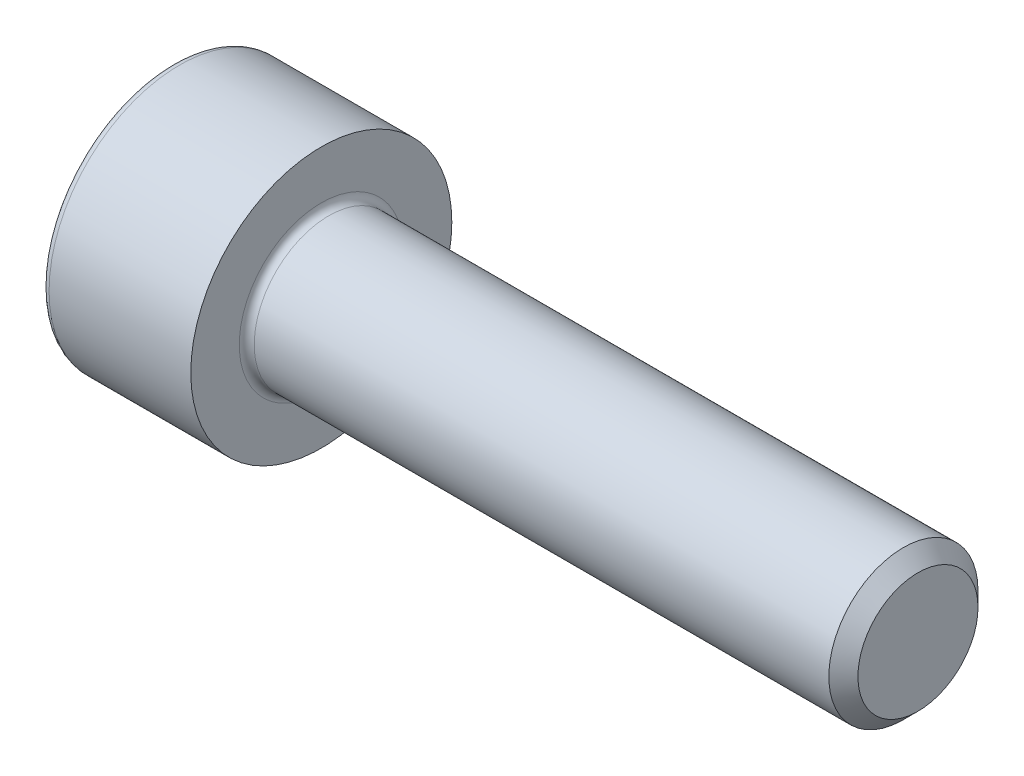
from build123d import *

# Parameters (mm, degrees)
ESBO_O1_W                = 4
ESBO_O1_H                = 3.5
ESBO_O2_R                = 2
RESSALTO_EXTRUS_O1_DEPTH = 16
CORTE_EXTRUS_O1_DEPTH    = 2
CHANFRO1_SIZE            = 0.39
FILETE1_R                = 0.2


with BuildPart() as part:
    # Esboço1 → Revolução1 (revolve)
    with BuildSketch(Plane(origin=(0, 0, 0), x_dir=(-1, 0, 0), z_dir=(0, 0, -1))):
        with Locations((-2, 1.75)):
            Rectangle(ESBO_O1_W, ESBO_O1_H)
    revolve(axis=Axis((4, 0, 0), (-1, 0, 0)))

    # Esboço2 → Ressalto-extrusão1 (add)
    with BuildSketch(Plane(origin=(4, 0, 0), x_dir=(0, 0, -1), z_dir=(1, 0, 0))):
        Circle(ESBO_O2_R)
    extrude(amount=RESSALTO_EXTRUS_O1_DEPTH)

    # Esboço3 → Corte-extrusão1 (cut)
    with BuildSketch(Plane.ZY):
        Polygon((0, -1.773042677), (1.5355, -0.886521338), (1.5355, 0.886521338), (0, 1.773042677), (-1.5355, 0.886521338), (-1.5355, -0.886521338), align=None)
    extrude(amount=-CORTE_EXTRUS_O1_DEPTH, mode=Mode.SUBTRACT)

    # Esboço4 → Corte-Revolução1 (revolve, cut)
    with BuildSketch(Plane.XY):
        Polygon((2, 1.5355), (2, 0), (2.886521338, 0), align=None)
    revolve(axis=Axis((2, 0, 0), (1, 0, 0)), mode=Mode.SUBTRACT)

    # Chanfro1
    chanfro1_edges = [part.edges().sort_by_distance(p)[0] for p in [
        (20, 0, 2),
    ]]
    chamfer(chanfro1_edges, length=CHANFRO1_SIZE)

    # Filete1
    filete1_edges = [part.edges().sort_by_distance(p)[0] for p in [
        (0, -3.5, 0),
        (4, 0, 2),
    ]]
    fillet(filete1_edges, radius=FILETE1_R)


solid = part.part
